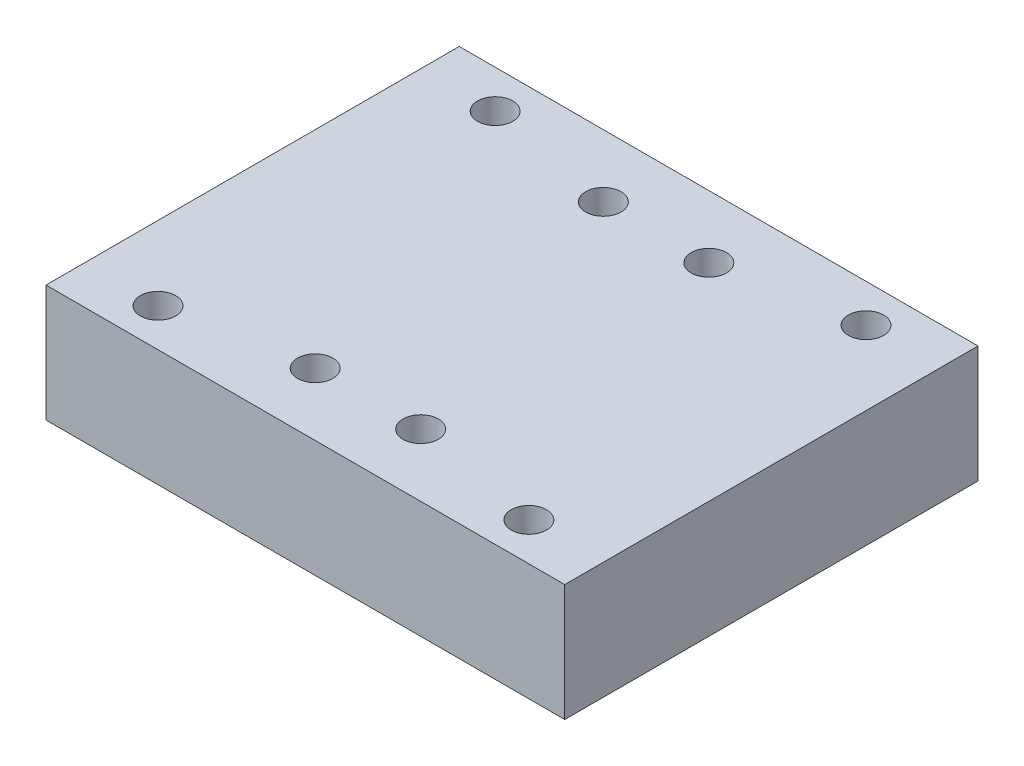
from build123d import *

# Parameters (mm, degrees)
SKETCH1_W                                  = 95.4
SKETCH1_H                                  = 76
BOSS_EXTRUDE1_DEPTH                        = 21.5
SKETCH2_R                                  = 3.25
CUT_EXTRUDE1_DEPTH                         = 22.5
MIRROR1_AT_THE_SECOND_PLANE_COPY_1_SKETC_R = 3.25
MIRROR1_AT_THE_SECOND_PLANE_COPY_1_DEPTH   = 22.5


with BuildPart() as part:
    # Sketch1 → Boss-Extrude1 (new body)
    with BuildSketch(Plane(origin=(0, 0, 0), x_dir=(1, 0, 0), z_dir=(0, 1, 0))):
        Rectangle(SKETCH1_W, SKETCH1_H)
    extrude(amount=BOSS_EXTRUDE1_DEPTH)

    # Sketch2 → Cut-Extrude1 (cut, through all)
    with BuildSketch(Plane(origin=(0, 21.5, 0), x_dir=(1, 0, 0), z_dir=(0, 1, 0))):
        with Locations((-34.1, 31)):
            Circle(SKETCH2_R)
        with Locations((-9.7, 26.5)):
            Circle(SKETCH2_R)
    cut_extrude1 = extrude(amount=-CUT_EXTRUDE1_DEPTH, mode=Mode.SUBTRACT)

    # Mirror1: Cut-Extrude1 across plane
    add(cut_extrude1.mirror(Plane(origin=(0, 0, 0), x_dir=(0, 0, 1), z_dir=(1, 0, 0))), mode=Mode.SUBTRACT)

    # Mirror1 at the second plane: Cut-Extrude1 across plane
    add(cut_extrude1.mirror(Plane.XY), mode=Mode.SUBTRACT)

    # Mirror1 at the second plane copy 1 sketc → Mirror1 at the second plane copy 1 (cut, through all)
    with BuildSketch(Plane(origin=(0, 21.5, 0), x_dir=(-1, 0, 0), z_dir=(0, 1, 0))):
        with Locations((-34.1, 31)):
            Circle(MIRROR1_AT_THE_SECOND_PLANE_COPY_1_SKETC_R)
        with Locations((-9.7, 26.5)):
            Circle(MIRROR1_AT_THE_SECOND_PLANE_COPY_1_SKETC_R)
    extrude(amount=-MIRROR1_AT_THE_SECOND_PLANE_COPY_1_DEPTH, mode=Mode.SUBTRACT)


solid = part.part
